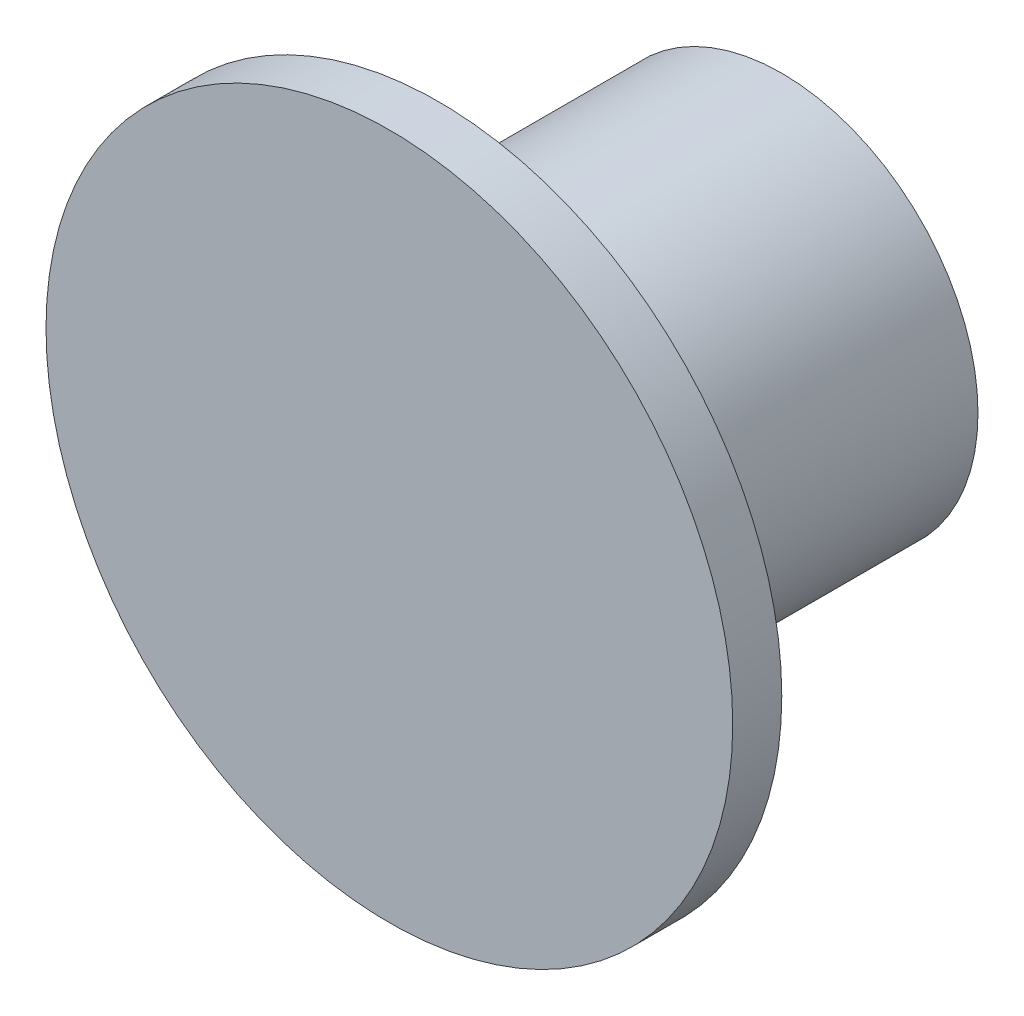
from build123d import *

# Parameters (mm, degrees)
SKETCH1_R           = 4
BOSS_EXTRUDE1_DEPTH = 7
SKETCH2_R           = 7
BOSS_EXTRUDE2_DEPTH = 1


with BuildPart() as part:
    # Sketch1 → Boss-Extrude1 (new body)
    with BuildSketch(Plane.XY):
        Circle(SKETCH1_R)
    extrude(amount=BOSS_EXTRUDE1_DEPTH)

    # Sketch2 → Boss-Extrude2 (add)
    with BuildSketch(Plane.XY.offset(7)):
        Circle(SKETCH2_R)
    extrude(amount=BOSS_EXTRUDE2_DEPTH)


solid = part.part
